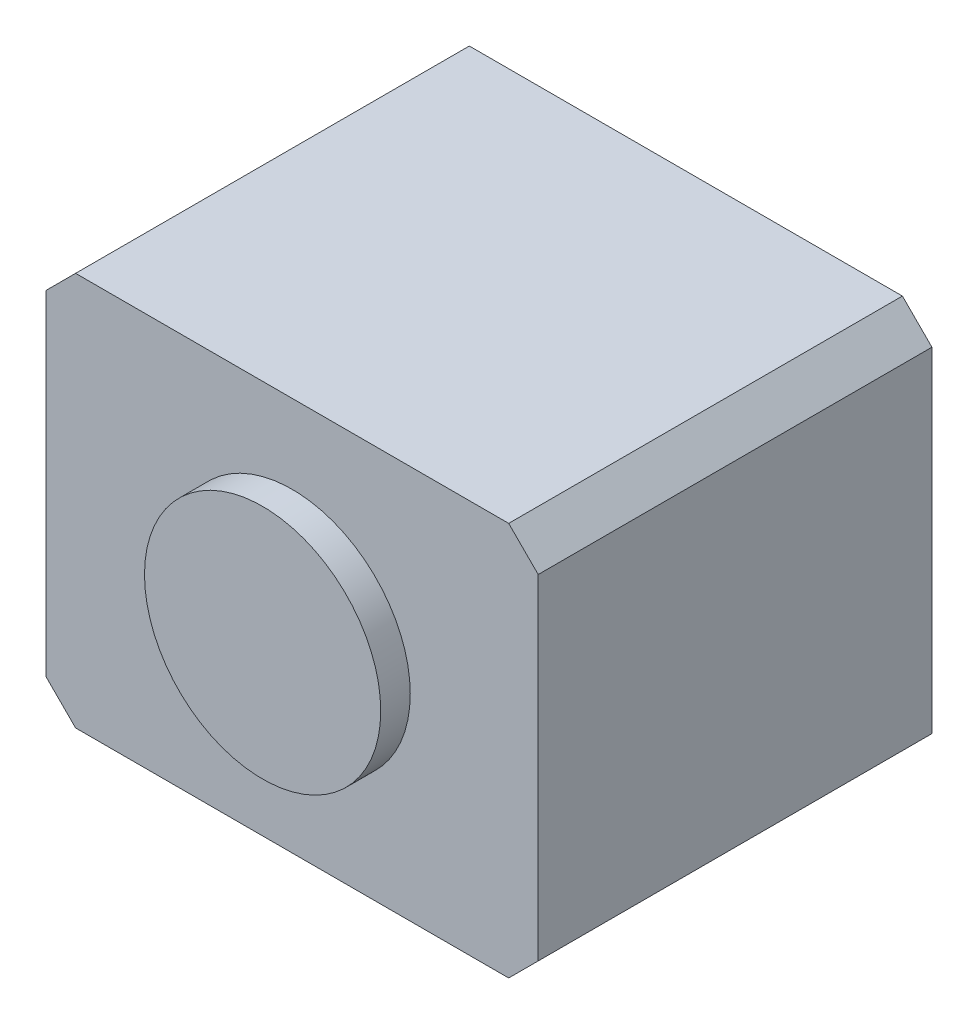
from build123d import *

# Parameters (mm, degrees)
SKETCH2_W           = 25
SKETCH2_H           = 20
BOSS_EXTRUDE1_DEPTH = 20
CHAMFER1_SIZE       = 1.5
SKETCH3_R           = 6
BOSS_EXTRUDE2_DEPTH = 1.5


with BuildPart() as part:
    # Sketch2 → Boss-Extrude1 (new body)
    with BuildSketch(Plane.XY):
        Rectangle(SKETCH2_W, SKETCH2_H)
    extrude(amount=BOSS_EXTRUDE1_DEPTH)

    # Chamfer1
    chamfer1_edges = [part.edges().sort_by_distance(p)[0] for p in [
        (12.5, -10, 10),
        (-12.5, -10, 10),
        (-12.5, 10, 10),
        (12.5, 10, 10),
    ]]
    chamfer(chamfer1_edges, length=CHAMFER1_SIZE)

    # Sketch3 → Boss-Extrude2 (add)
    with BuildSketch(Plane.XY.offset(20)):
        Circle(SKETCH3_R)
    extrude(amount=BOSS_EXTRUDE2_DEPTH)


solid = part.part
